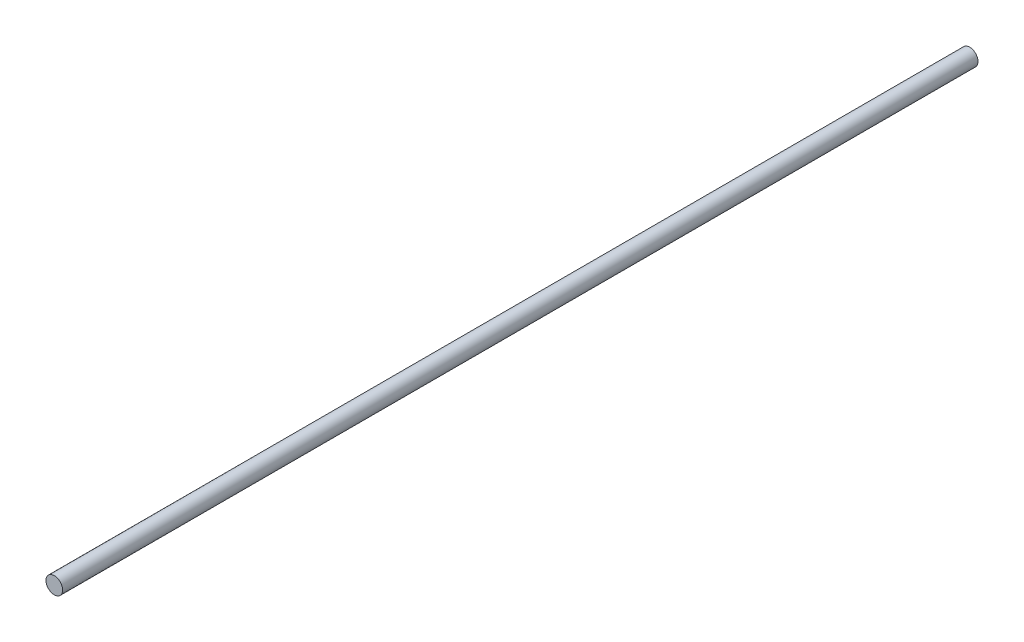
from build123d import *

# Parameters (mm, degrees)
ESQUISSE1_R        = 4
BOSS_EXTRU_1_DEPTH = 440


with BuildPart() as part:
    # Esquisse1 → Boss.-Extru.1 (new body)
    with BuildSketch(Plane.XY):
        Circle(ESQUISSE1_R)
    extrude(amount=BOSS_EXTRU_1_DEPTH)


solid = part.part
